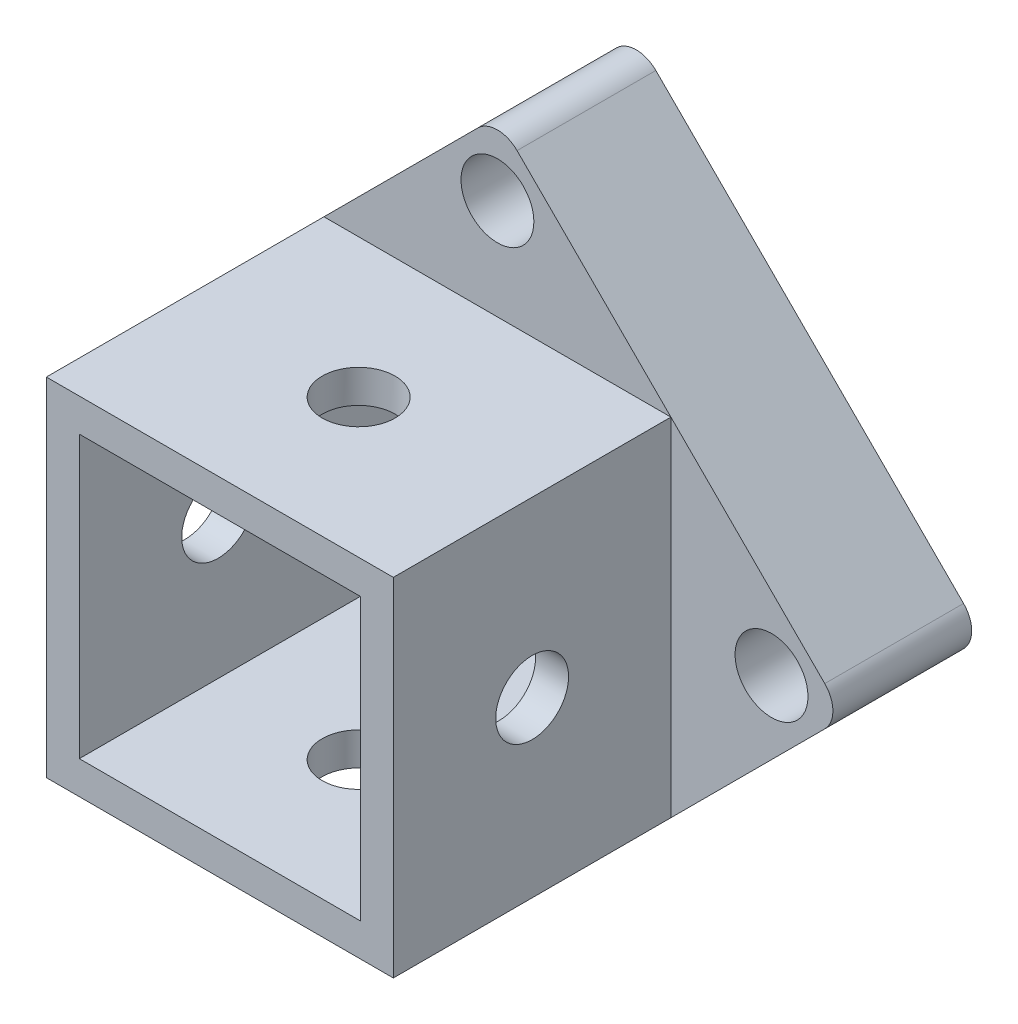
from build123d import *

# Parameters (mm, degrees)
SKETCH1_W           = 25
SKETCH1_H           = 25
SKETCH1_W_2         = 20.25
SKETCH1_H_2         = 20.25
BOSS_EXTRUDE1_DEPTH = 5
SKETCH2_R           = 2.625
SKETCH2_W           = 20.25
SKETCH2_H           = 20.25
BOSS_EXTRUDE2_DEPTH = 5
SKETCH3_W           = 25
SKETCH3_H           = 25
SKETCH3_W_2         = 20.25
SKETCH3_H_2         = 20.25
BOSS_EXTRUDE3_DEPTH = 20
SKETCH4_R           = 2.625
CUT_EXTRUDE1_DEPTH  = 38.5
SKETCH5_R           = 2.625
CUT_EXTRUDE2_DEPTH  = 38.5
FILLET1_R           = 2


with BuildPart() as part:
    # Sketch1 → Boss-Extrude1 (new body, symmetric)
    with BuildSketch(Plane.XY):
        Rectangle(SKETCH1_W, SKETCH1_H)
        Rectangle(SKETCH1_W_2, SKETCH1_H_2, mode=Mode.SUBTRACT)
    extrude(amount=BOSS_EXTRUDE1_DEPTH, both=True)

    # Sketch2 → Boss-Extrude2 (add, symmetric)
    with BuildSketch(Plane.XY):
        Polygon((-25, 0), (0, 25), (25, 0), (0, -25), align=None)
        with Locations((0, 19.75)):
            Circle(SKETCH2_R, mode=Mode.SUBTRACT)
        with Locations((19.75, 0)):
            Circle(SKETCH2_R, mode=Mode.SUBTRACT)
        with Locations((0, -19.75)):
            Circle(SKETCH2_R, mode=Mode.SUBTRACT)
        with Locations((-19.75, 0)):
            Circle(SKETCH2_R, mode=Mode.SUBTRACT)
        Rectangle(SKETCH2_W, SKETCH2_H, mode=Mode.SUBTRACT)
    extrude(amount=BOSS_EXTRUDE2_DEPTH, both=True)

    # Sketch3 → Boss-Extrude3 (add)
    with BuildSketch(Plane.XY.offset(5)):
        Rectangle(SKETCH3_W, SKETCH3_H)
        Rectangle(SKETCH3_W_2, SKETCH3_H_2, mode=Mode.SUBTRACT)
    extrude(amount=BOSS_EXTRUDE3_DEPTH)

    # Sketch4 → Cut-Extrude1 (cut, through all)
    with BuildSketch(Plane(origin=(0, 12.5, 0), x_dir=(1, 0, 0), z_dir=(0, 1, 0))):
        with Locations((0, -15)):
            Circle(SKETCH4_R)
    extrude(amount=-CUT_EXTRUDE1_DEPTH, mode=Mode.SUBTRACT)

    # Sketch5 → Cut-Extrude2 (cut, through all)
    with BuildSketch(Plane(origin=(12.5, 0, 0), x_dir=(0, 0, -1), z_dir=(1, 0, 0))):
        with Locations((-15, 0)):
            Circle(SKETCH5_R)
    extrude(amount=-CUT_EXTRUDE2_DEPTH, mode=Mode.SUBTRACT)

    # Fillet1
    fillet1_edges = [part.edges().sort_by_distance(p)[0] for p in [
        (0, -25, 0),
        (25, 0, 0),
        (0, 25, 0),
        (-25, 0, 0),
    ]]
    fillet(fillet1_edges, radius=FILLET1_R)


solid = part.part
